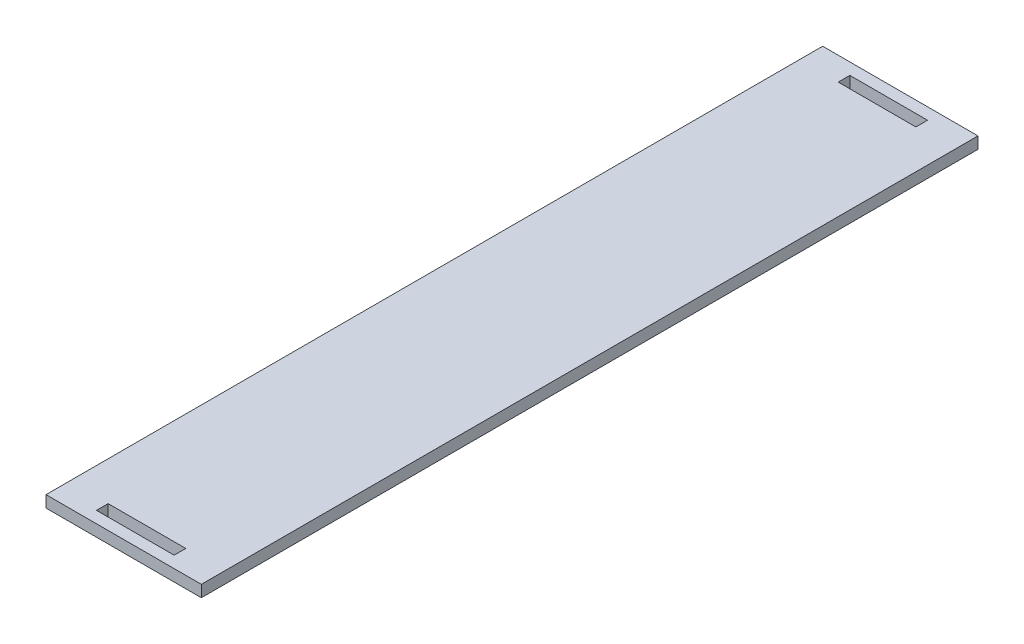
from build123d import *

# Parameters (mm, degrees)
ESQUISSE1_W        = 40
ESQUISSE1_H        = 200
ESQUISSE1_W_2      = 20
ESQUISSE1_H_2      = 3
BOSS_EXTRU_1_DEPTH = 3


with BuildPart() as part:
    # Esquisse1 → Boss.-Extru.1 (new body)
    with BuildSketch(Plane(origin=(0, 0, 0), x_dir=(1, 0, 0), z_dir=(0, 1, 0))):
        Rectangle(ESQUISSE1_W, ESQUISSE1_H)
        with Locations((0, -95.5)):
            Rectangle(ESQUISSE1_W_2, ESQUISSE1_H_2, mode=Mode.SUBTRACT)
        with Locations((0, 95.5)):
            Rectangle(ESQUISSE1_W_2, ESQUISSE1_H_2, mode=Mode.SUBTRACT)
    extrude(amount=BOSS_EXTRU_1_DEPTH)


solid = part.part
